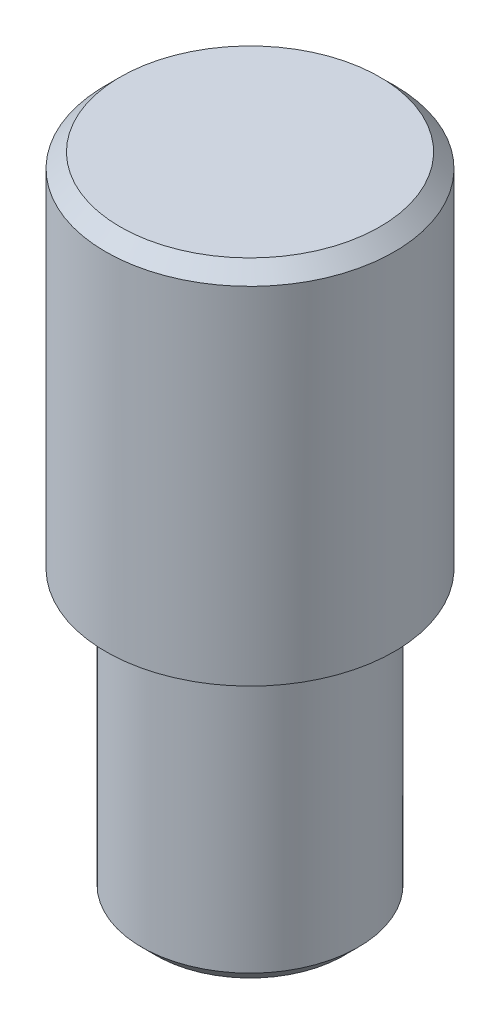
from build123d import *

# Parameters (mm, degrees)
CHAMFER_1_SIZE = 1


with BuildPart() as part:
    # 草图1 → 旋转1 (revolve)
    with BuildSketch(Plane.XY):
        Polygon((0, 0), (10, 0), (10, -25), (7.5, -25), (7.5, -45), (0, -45), align=None)
    revolve(axis=Axis((0, -45, 0), (0, 1, 0)))

    # 倒角1
    chamfer_1_edges = [part.edges().sort_by_distance(p)[0] for p in [
        (-7.5, -45, 0),
        (-10, 0, 0),
    ]]
    chamfer(chamfer_1_edges, length=CHAMFER_1_SIZE)


solid = part.part
